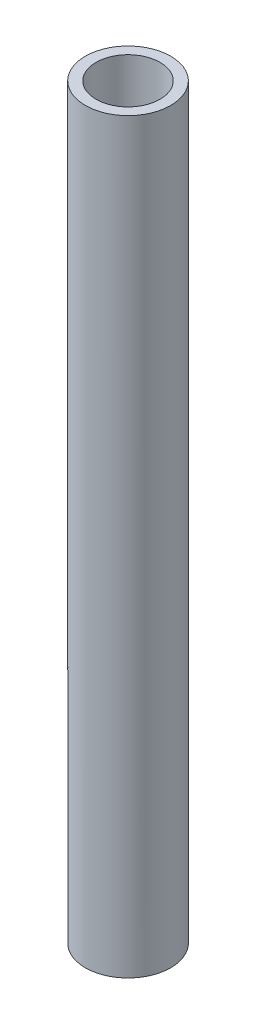
from build123d import *

# Parameters (mm, degrees)
SKETCH1_R           = 12.7
SKETCH1_R_2         = 9.525
BOSS_EXTRUDE1_DEPTH = 222.25


with BuildPart() as part:
    # Sketch1 → Boss-Extrude1 (new body)
    with BuildSketch(Plane(origin=(0, 0, 0), x_dir=(1, 0, 0), z_dir=(0, 1, 0))):
        Circle(SKETCH1_R)
        Circle(SKETCH1_R_2, mode=Mode.SUBTRACT)
    extrude(amount=BOSS_EXTRUDE1_DEPTH)


solid = part.part
